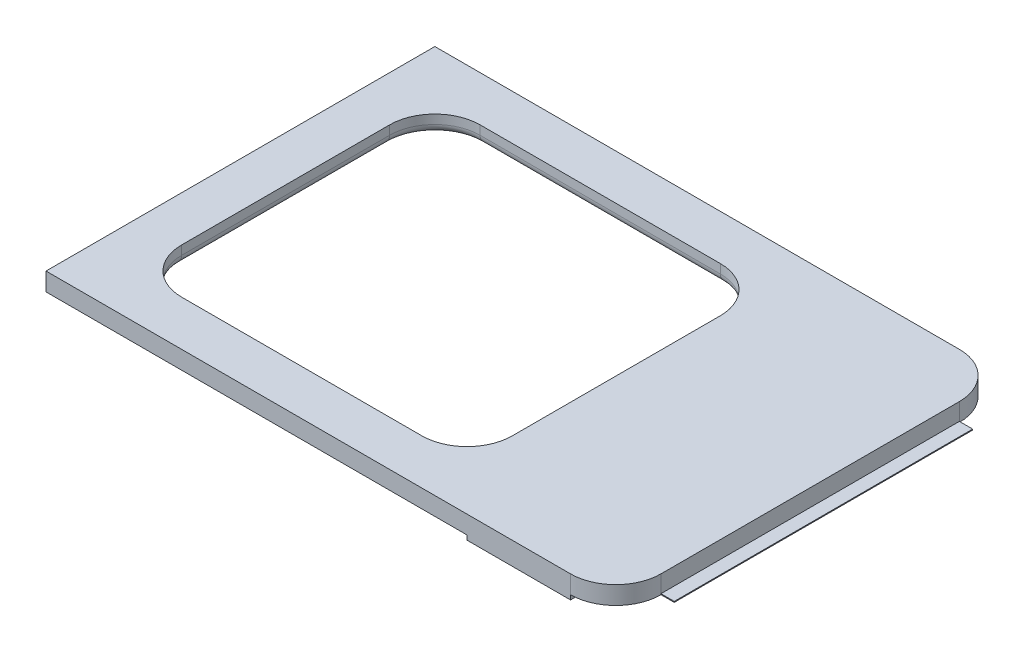
from build123d import *

# Parameters (mm, degrees)
BOSS_EXTRUDE1_DEPTH = 2
SKETCH3_W           = 1.47
SKETCH3_H           = 33
BOSS_EXTRUDE3_DEPTH = 0.1
SKETCH4_W           = 11.437084048
SKETCH4_H           = 43
BOSS_EXTRUDE4_DEPTH = 0.5
SKETCH5_R           = 3.25
BOSS_EXTRUDE5_DEPTH = 1
BOSS_EXTRUDE6_DEPTH = 0.7
CUT_EXTRUDE2_DEPTH  = 10
FILLET4_R           = 1
SKETCH7_R           = 1.432474787
BOSS_EXTRUDE7_DEPTH = 0.7


with BuildPart() as part:
    # Sketch1 → Boss-Extrude1 (new body)
    with BuildSketch(Plane(origin=(0, 0, 0), x_dir=(1, 0, 0), z_dir=(0, 1, 0))):
        with BuildLine():
            Line((-26.5, 21.5), (-31.5, 21.5))
            Line((-31.5, 21.5), (-31.5, 16.5))
            Line((-31.5, 16.5), (-31.5, -16.5))
            Line((-31.5, -16.5), (-31.5, -21.5))
            Line((-31.5, -21.5), (-26.5, -21.5))
            Line((-26.5, -21.5), (26.5, -21.5))
            ThreePointArc((26.5, -21.5), (30.035533906, -20.035533906), (31.5, -16.5))
            Line((31.5, -16.5), (31.5, 16.5))
            ThreePointArc((31.5, 16.5), (30.035533906, 20.035533906), (26.5, 21.5))
            Line((26.5, 21.5), (-26.5, 21.5))
        make_face()
    extrude(amount=BOSS_EXTRUDE1_DEPTH)

    # Sketch3 → Boss-Extrude3 (add)
    with BuildSketch(Plane(origin=(0, 0, 0), x_dir=(1, 0, 0), z_dir=(0, 1, 0))):
        with Locations((32.235, 0)):
            Rectangle(SKETCH3_W, SKETCH3_H)
    extrude(amount=BOSS_EXTRUDE3_DEPTH)

    # Sketch4 → Boss-Extrude4 (add)
    with BuildSketch(Plane.XZ):
        with Locations((20.781457976, 0)):
            Rectangle(SKETCH4_W, SKETCH4_H)
    extrude(amount=BOSS_EXTRUDE4_DEPTH)

    # Sketch5 → Boss-Extrude5 (add)
    with BuildSketch(Plane.XZ.offset(0.5)):
        with Locations((20.781457976, -10.75)):
            Circle(SKETCH5_R)
        with Locations((20.781457976, 0)):
            Circle(SKETCH5_R)
        with Locations((20.781457976, 10.75)):
            Circle(SKETCH5_R)
    extrude(amount=BOSS_EXTRUDE5_DEPTH)

    # Sketch6 → Boss-Extrude6 (add)
    with BuildSketch(Plane.XZ.offset(1.5)):
        Polygon((22.728056174, 9.551943968), (20.845705836, 13.034831506), (18.770611919, 9.663224526), align=None)
        Polygon((20.781457976, -2.122654215), (22.61973045, 1.061327108), (18.943185502, 1.061327108), align=None)
    extrude(amount=BOSS_EXTRUDE6_DEPTH)

    # Sketch9 → Cut-Extrude2 (cut)
    with BuildSketch(Plane(origin=(0, 0, 0), x_dir=(-1, 0, 0), z_dir=(0, -1, 0))):
        with BuildLine():
            Line((-5.062915952, 16.5), (21.5, 16.5))
            ThreePointArc((21.5, 16.5), (25.035533906, 15.035533906), (26.5, 11.5))
            Line((26.5, 11.5), (26.5, -11.5))
            ThreePointArc((26.5, -11.5), (25.035533906, -15.035533906), (21.5, -16.5))
            Line((21.5, -16.5), (-5.062915952, -16.5))
            ThreePointArc((-5.062915952, -16.5), (-8.598449858, -15.035533906), (-10.062915952, -11.5))
            Line((-10.062915952, -11.5), (-10.062915952, 11.5))
            ThreePointArc((-10.062915952, 11.5), (-8.598449858, 15.035533906), (-5.062915952, 16.5))
        make_face()
    extrude(amount=-CUT_EXTRUDE2_DEPTH, mode=Mode.SUBTRACT)

    # Fillet4
    fillet4_edges = [part.edges().sort_by_distance(p)[0] for p in [
        (8.598449858, 0, 15.035533906),
        (-8.218542024, 0, 16.5),
        (-25.035533906, 0, 15.035533906),
        (-26.5, 0, 0),
        (-25.035533906, 0, -15.035533906),
        (-8.218542024, 0, -16.5),
        (8.598449858, 0, -15.035533906),
        (10.062915952, 0, 0),
    ]]
    fillet(fillet4_edges, radius=FILLET4_R)

    # Sketch7 → Boss-Extrude7 (add)
    with BuildSketch(Plane(origin=(0, -1.5, 0), x_dir=(-1, 0, 0), z_dir=(0, -1, 0))):
        with Locations((-20.781457976, 10.75)):
            Circle(SKETCH7_R)
    extrude(amount=BOSS_EXTRUDE7_DEPTH)


solid = part.part
